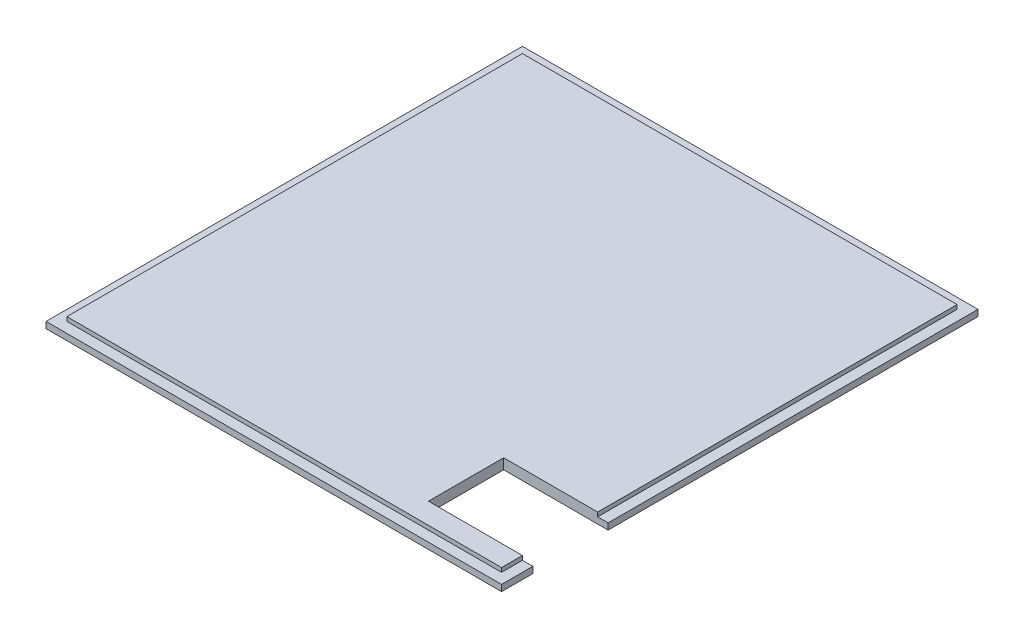
from build123d import *

# Parameters (mm, degrees)
SKETCH2_W           = 109
SKETCH2_H           = 114
BOSS_EXTRUDE1_DEPTH = 1.5
SKETCH3_W           = 104
SKETCH3_H           = 109
BOSS_EXTRUDE2_DEPTH = 1
SKETCH4_W           = 25
SKETCH4_H           = 18
CUT_EXTRUDE1_DEPTH  = 2.5


with BuildPart() as part:
    # Sketch2 → Boss-Extrude1 (new body)
    with BuildSketch(Plane(origin=(0, 0, 0), x_dir=(1, 0, 0), z_dir=(0, 1, 0))):
        Rectangle(SKETCH2_W, SKETCH2_H)
    extrude(amount=BOSS_EXTRUDE1_DEPTH)

    # Sketch3 → Boss-Extrude2 (add)
    with BuildSketch(Plane(origin=(0, 1.5, 0), x_dir=(1, 0, 0), z_dir=(0, 1, 0))):
        Rectangle(SKETCH3_W, SKETCH3_H)
    extrude(amount=BOSS_EXTRUDE2_DEPTH)

    # Sketch4 → Cut-Extrude1 (cut)
    with BuildSketch(Plane(origin=(0, 2.5, 0), x_dir=(1, 0, 0), z_dir=(0, 1, 0))):
        with Locations((42, -40.5)):
            Rectangle(SKETCH4_W, SKETCH4_H)
    extrude(amount=-CUT_EXTRUDE1_DEPTH, mode=Mode.SUBTRACT)


solid = part.part
